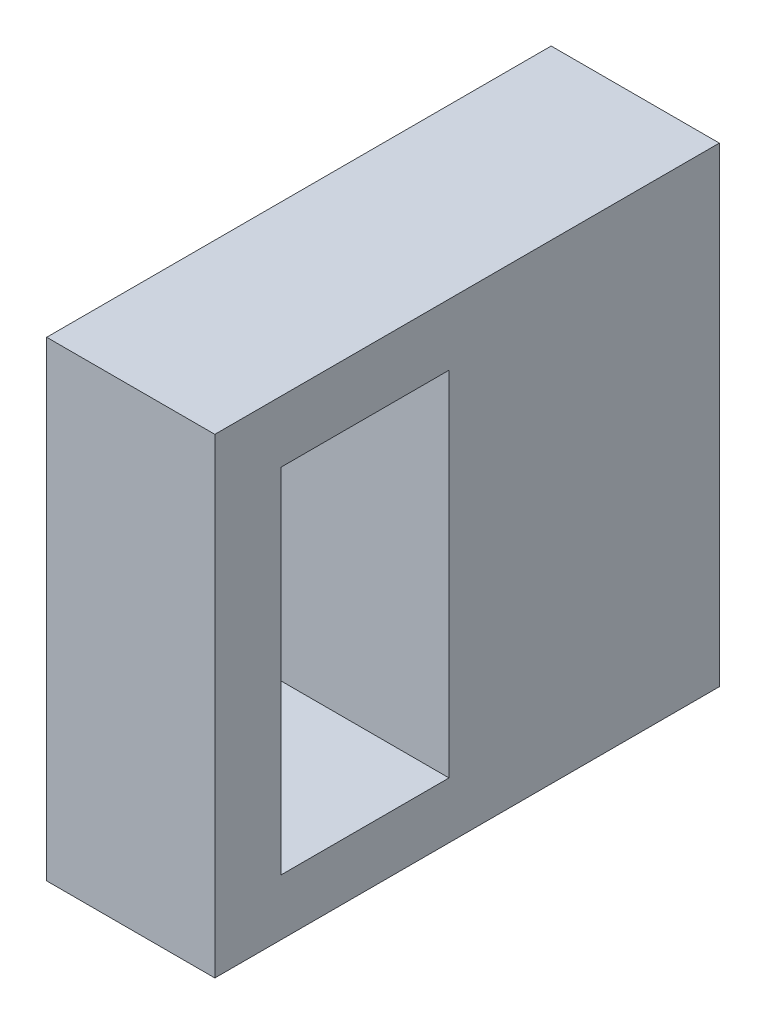
from build123d import *

# Parameters (mm, degrees)
CROQUIS1_W              = 12.7
CROQUIS1_H              = 35.56
SALIENTE_EXTRUIR1_DEPTH = 38.1
CROQUIS3_W              = 12.7
CROQUIS3_H              = 26.67
CORTAR_EXTRUIR1_DEPTH   = 38.1


with BuildPart() as part:
    # Croquis1 → Saliente-Extruir1 (new body)
    with BuildSketch(Plane.XY):
        with Locations((-37.495945778, 19.33754717)):
            Rectangle(CROQUIS1_W, CROQUIS1_H)
    extrude(amount=SALIENTE_EXTRUIR1_DEPTH)

    # Croquis3 → Cortar-Extruir1 (cut)
    with BuildSketch(Plane.ZY.offset(43.845945778)):
        with Locations((26.763723238, 19.135311011)):
            Rectangle(CROQUIS3_W, CROQUIS3_H)
    extrude(amount=-CORTAR_EXTRUIR1_DEPTH, mode=Mode.SUBTRACT)


solid = part.part
